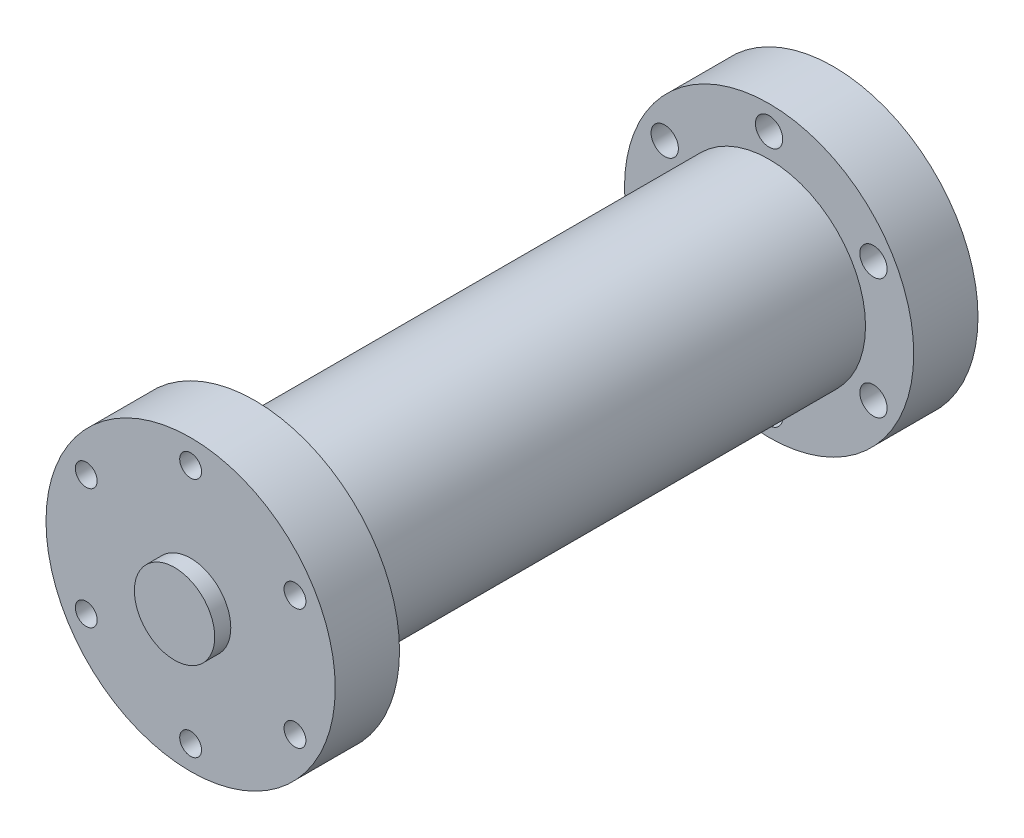
from build123d import *

# Parameters (mm, degrees)
SKETCH1_R                      = 45
BOSS_EXTRUDE1_DEPTH            = 20
SKETCH2_R                      = 30
BOSS_EXTRUDE2_DEPTH            = 160
SKETCH3_R                      = 45
BOSS_EXTRUDE3_DEPTH            = 20
SKETCH4_R                      = 12.5
BOSS_EXTRUDE4_DEPTH            = 5
M8X1_25_TAPPED_HOLE1_REACH     = 202
M8X1_25_TAPPED_HOLE1_BORE_R    = 3.4
CIRPATTERN1_COUNT              = 6
F_8_5_8_5_DIAMETER_HOLE1_D     = 8.5
F_8_5_8_5_DIAMETER_HOLE1_DEPTH = 20.001
CIRPATTERN2_COUNT              = 6
SKETCH11_R                     = 12.5
CUT_EXTRUDE1_DEPTH             = 60


with BuildPart() as part:
    # Sketch1 → Boss-Extrude1 (new body)
    with BuildSketch(Plane.XY):
        Circle(SKETCH1_R)
    extrude(amount=BOSS_EXTRUDE1_DEPTH)

    # Sketch2 → Boss-Extrude2 (add)
    with BuildSketch(Plane(origin=(0, 0, 0), x_dir=(-1, 0, 0), z_dir=(0, 0, -1))):
        Circle(SKETCH2_R)
    extrude(amount=BOSS_EXTRUDE2_DEPTH)

    # Sketch3 → Boss-Extrude3 (add)
    with BuildSketch(Plane(origin=(0, 0, -160), x_dir=(-1, 0, 0), z_dir=(0, 0, -1))):
        with Locations(Location((0, 0, 0), (0, 0, 180))):  # turned: the seam where the file's is
            Circle(SKETCH3_R)
    extrude(amount=BOSS_EXTRUDE3_DEPTH)

    # Sketch4 → Boss-Extrude4 (add)
    with BuildSketch(Plane.XY.offset(20)):
        Circle(SKETCH4_R)
    extrude(amount=BOSS_EXTRUDE4_DEPTH)

    # M8x1.25 Tapped Hole1 bore → M8x1.25 Tapped Hole1 (cut, up to next)
    with BuildSketch(Plane.XY.offset(20), mode=Mode.PRIVATE) as m8x1_25_tapped_hole1_sk1:
        with Locations((0, 37.5)):
            Circle(M8X1_25_TAPPED_HOLE1_BORE_R)
    m8x1_25_tapped_hole1_tool1 = extrude(m8x1_25_tapped_hole1_sk1.sketch, amount=-M8X1_25_TAPPED_HOLE1_REACH, mode=Mode.PRIVATE) & part.part
    m8x1_25_tapped_hole1 = m8x1_25_tapped_hole1_tool1.solids().sort_by_distance((0, 37.5, 20))[0]
    add(m8x1_25_tapped_hole1, mode=Mode.SUBTRACT)

    # CirPattern1: M8x1.25 Tapped Hole1 ×6 about axis
    cirpattern1_axis = Axis((0, 0, 0), (0, 0, 1))
    for i in range(1, CIRPATTERN1_COUNT):
        add(m8x1_25_tapped_hole1.rotate(cirpattern1_axis, i * 360 / CIRPATTERN1_COUNT), mode=Mode.SUBTRACT)

    # Ø8.5 (8.5) Diameter Hole1
    with Locations(Plane(origin=(0, 0, -180), x_dir=(-1, 0, 0), z_dir=(0, 0, -1))):
        with Locations((0, 37.5)):
            f_8_5_8_5_diameter_hole1 = Hole(F_8_5_8_5_DIAMETER_HOLE1_D / 2, depth=F_8_5_8_5_DIAMETER_HOLE1_DEPTH)

    # CirPattern2: Ø8.5 (8.5) Diameter Hole1 ×6 about axis
    cirpattern2_axis = Axis((0, 0, 0), (0, 0, 1))
    for i in range(1, CIRPATTERN2_COUNT):
        add(f_8_5_8_5_diameter_hole1.rotate(cirpattern2_axis, i * 360 / CIRPATTERN2_COUNT), mode=Mode.SUBTRACT)

    # Sketch11 → Cut-Extrude1 (cut)
    with BuildSketch(Plane(origin=(0, 0, -180), x_dir=(-1, 0, 0), z_dir=(0, 0, -1))):
        with Locations(Location((0, 0, 0), (0, 0, 180))):  # turned: the seam where the file's is
            Circle(SKETCH11_R)
    extrude(amount=-CUT_EXTRUDE1_DEPTH, mode=Mode.SUBTRACT)


solid = part.part
